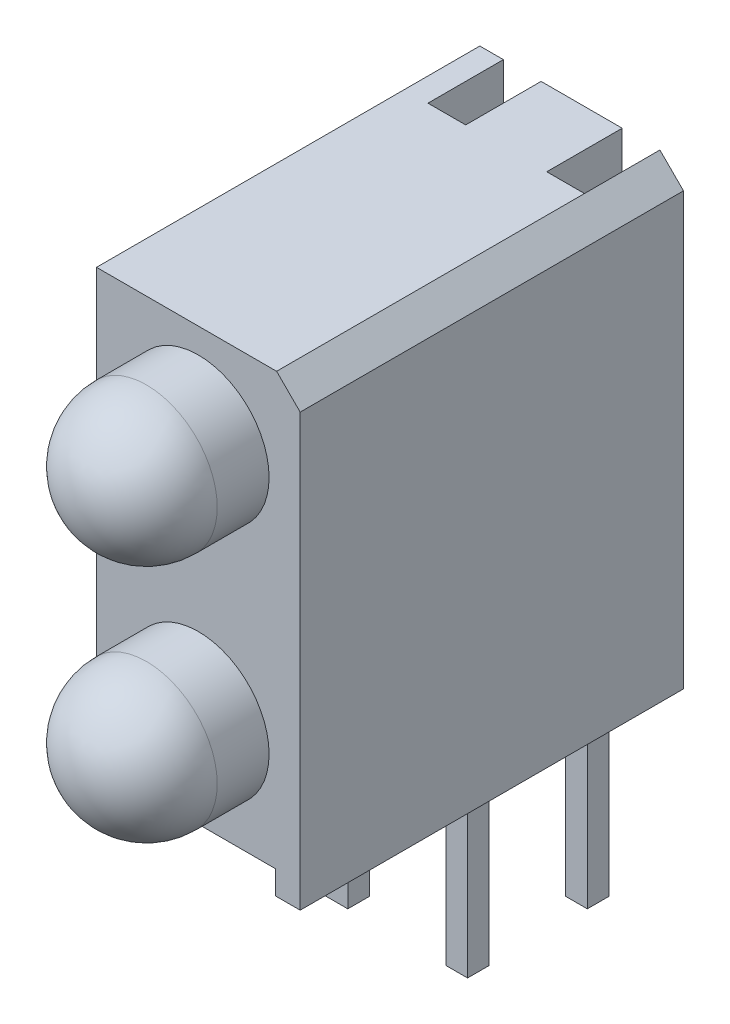
from build123d import *

# Parameters (mm, degrees)
EXTRUSION1_DEPTH   = 8.13
ESQUISSE2_W        = 0.8
ESQUISSE2_H        = 1.6
EXTRUSION2_DEPTH   = 10.55
ESQUISSE4_W        = 0.78
ESQUISSE4_H        = 2.54
EXTRUSION3_DEPTH   = 0.5
ESQUISSE5_W        = 0.46
ESQUISSE5_H        = 0.46
EXTRUSION4_DEPTH   = 4.68
ESQUISSE6_W        = 0.46
ESQUISSE6_H        = 0.46
EXTRUSION5_DEPTH   = 11.53
EXTRUSION5_2_DEPTH = 11.53
ESQUISSE7_W        = 0.46
ESQUISSE7_H        = 0.46
EXTRUSION6_DEPTH   = 0.22


with BuildPart() as part:
    # Esquisse1 → Extrusion1 (new body)
    with BuildSketch(Plane.XY):
        Polygon((-3.8, 0), (-3.8, 0.5), (-0.52, 0.5), (-0.52, 0), (0, 0), (0, 9.15), (-0.5, 9.65), (-4.32, 9.65), (-4.32, 0), align=None)
    extrude(amount=EXTRUSION1_DEPTH)

    # Esquisse2 → Extrusion2 (cut)
    with BuildSketch(Plane(origin=(0, 9.65, 0), x_dir=(1, 0, 0), z_dir=(0, 1, 0))):
        with Locations((-0.9, -0.8)):
            Rectangle(ESQUISSE2_W, ESQUISSE2_H)
        with Locations((-3.42, -0.8)):
            Rectangle(ESQUISSE2_W, ESQUISSE2_H)
    extrude(amount=-EXTRUSION2_DEPTH, mode=Mode.SUBTRACT)

    # Esquisse4 → Extrusion3 (cut)
    with BuildSketch(Plane.XZ.offset(-0.5)):
        with Locations((-3.41, 2.87)):
            Rectangle(ESQUISSE4_W, ESQUISSE4_H)
        with Locations((-0.91, 2.87)):
            Rectangle(ESQUISSE4_W, ESQUISSE4_H)
    extrude(amount=-EXTRUSION3_DEPTH, mode=Mode.SUBTRACT)

    # Esquisse5 → Extrusion4 (add)
    with BuildSketch(Plane.XZ.offset(3.68)):
        with Locations((-3.43, 3.69)):
            Rectangle(ESQUISSE5_W, ESQUISSE5_H)
        with Locations((-0.89, 3.69)):
            Rectangle(ESQUISSE5_W, ESQUISSE5_H)
    extrude(amount=-EXTRUSION4_DEPTH)



with BuildPart() as body_2:
    # Esquisse6 → Extrusion5 (new body)
    with BuildSketch(Plane.XZ.offset(3.68)):
        with Locations((-3.43, 1.15)):
            Rectangle(ESQUISSE6_W, ESQUISSE6_H)
    extrude(amount=-EXTRUSION5_DEPTH)


with BuildPart() as body_3:
    # Esquisse6 → Extrusion5 2 (new body)
    with BuildSketch(Plane.XZ.offset(3.68)):
        with Locations((-0.89, 1.15)):
            Rectangle(ESQUISSE6_W, ESQUISSE6_H)
    extrude(amount=-EXTRUSION5_2_DEPTH)


with BuildPart() as part_1:
    add(part.part)

    add(body_2.part)  # Extrusion6 merges body 2

    add(body_3.part)  # Extrusion6 merges body 3
    # Esquisse7 → Extrusion6 (add)
    with BuildSketch(Plane.XY.offset(1.38)):
        with Locations((-0.89, 7.62)):
            Rectangle(ESQUISSE7_W, ESQUISSE7_H)
        with Locations((-3.43, 7.62)):
            Rectangle(ESQUISSE7_W, ESQUISSE7_H)
    extrude(amount=EXTRUSION6_DEPTH)

    # Esquisse9 → Révolution1 (revolve)
    with BuildSketch(Plane(origin=(-2.16, 0, 0), x_dir=(0, 0, -1), z_dir=(1, 0, 0))):
        with BuildLine():
            Line((-9.23, 1.04), (-8.13, 1.04))
            Line((-8.13, 1.04), (-8.13, 2.54))
            Line((-8.13, 2.54), (-10.73, 2.54))
            ThreePointArc((-10.73, 2.54), (-10.290660172, 1.479339828), (-9.23, 1.04))
        make_face()
    revolve(axis=Axis((-2.16, 2.54, 13.741236879), (0, 0, -1)))

    # Esquisse10 → Révolution2 (revolve)
    with BuildSketch(Plane(origin=(-2.16, 0, 0), x_dir=(0, 0, -1), z_dir=(1, 0, 0))):
        with BuildLine():
            Line((-9.23, 6.12), (-8.13, 6.12))
            Line((-8.13, 6.12), (-8.13, 7.62))
            Line((-8.13, 7.62), (-10.73, 7.62))
            ThreePointArc((-10.73, 7.62), (-10.290660172, 6.559339828), (-9.23, 6.12))
        make_face()
    revolve(axis=Axis((-2.16, 7.62, 13.129927016), (0, 0, -1)))


solid = part_1.part
